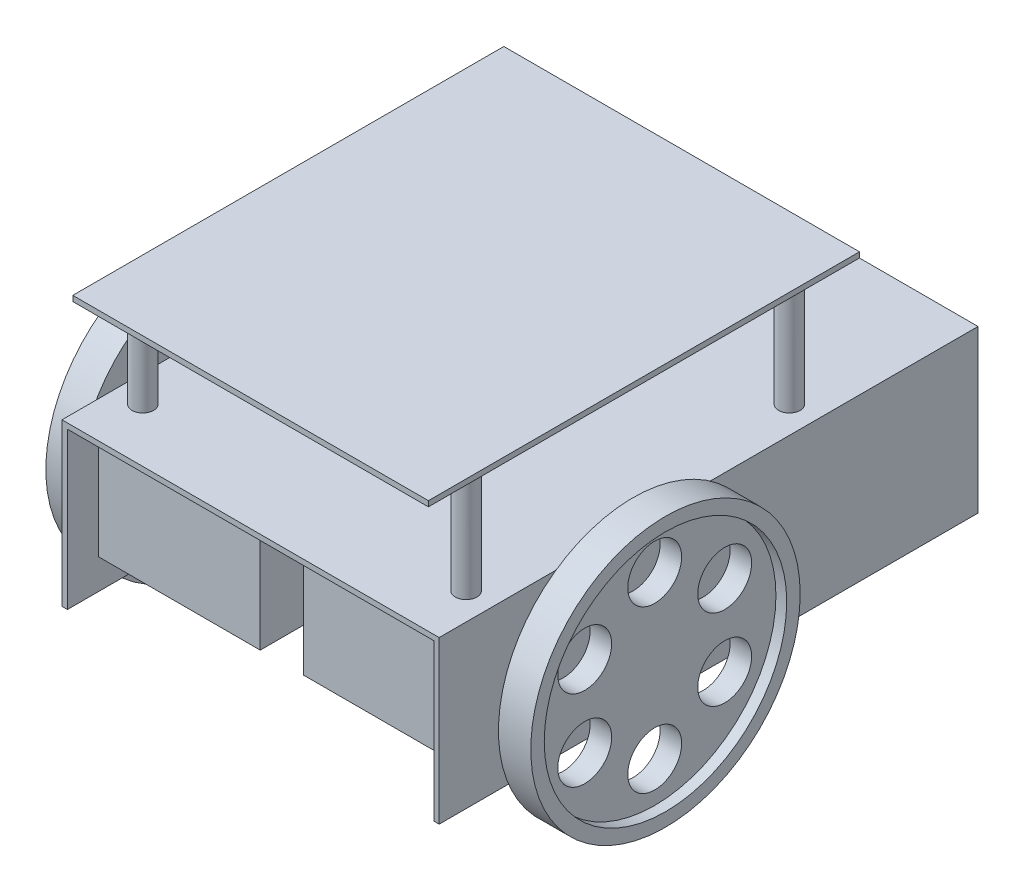
from build123d import *

# Parameters (mm, degrees)
SKETCH_1_W               = 70
SKETCH_1_H               = 100
EXTRUDE_1_DEPTH          = 30
SHELL_1_T                = -1
SKETCH_2_W               = 40
SKETCH_2_H               = 20
EXTRUDE_2_DEPTH          = 30
SKETCH_3_R               = 1.5
EXTRUDE_3_DEPTH          = 10
SKETCH_4_R               = 25
EXTRUDE_4_DEPTH          = 6
SKETCH_5_R               = 22.5
CUT_EXTRUDE_1_DEPTH      = 2
SKETCH_6_R               = 5
CUT_EXTRUDE_2_DEPTH      = 8
PATTERN_CIRCULAR_1_COUNT = 6
MIRROR_1_COPY_1_SKETCH_R = 5
MIRROR_1_COPY_1_DEPTH    = 8
MIRROR_1_COPY_2_SKETCH_R = 5
MIRROR_1_COPY_2_DEPTH    = 8
MIRROR_1_COPY_3_SKETCH_R = 5
MIRROR_1_COPY_3_DEPTH    = 8
MIRROR_1_COPY_4_SKETCH_R = 5
MIRROR_1_COPY_4_DEPTH    = 8
MIRROR_1_COPY_5_SKETCH_R = 5
MIRROR_1_COPY_5_DEPTH    = 8
SKETCH_9_R               = 14
CUT_EXTRUDE_4_DEPTH      = 8
SKETCH_8_W               = 3
SKETCH_8_H               = 29
CUT_EXTRUDE_3_DEPTH      = 8
SKETCH_10_R              = 1
EXTRUDE_5_DEPTH          = 14
SKETCH_11_R              = 2
EXTRUDE_6_DEPTH          = 20
SKETCH_12_W              = 66
SKETCH_12_H              = 80
EXTRUDE_7_DEPTH          = 1


with BuildPart() as part:
    # 草圖1 → 填料-伸長1 (new body)
    with BuildSketch(Plane(origin=(0, 0, 0), x_dir=(1, 0, 0), z_dir=(0, 1, 0))):
        with Locations((0, 50)):
            Rectangle(SKETCH_1_W, SKETCH_1_H)
    extrude(amount=EXTRUDE_1_DEPTH)

    # 薄殼1
    shell_1_openings = [part.faces().sort_by_distance(p)[0] for p in [
        (0, 0, -50),
        (0, 15, 0),
    ]]
    offset(amount=SHELL_1_T, openings=shell_1_openings, kind=Kind.INTERSECTION)

    # 草圖2 → 填料-伸長2 (add)
    with BuildSketch(Plane.ZY.offset(-34)):
        with Locations((-25.793166275, 15.578551741)):
            Rectangle(SKETCH_2_W, SKETCH_2_H)
    extrude_2 = extrude(amount=EXTRUDE_2_DEPTH)

    # 草圖3 → 填料-伸長3 (add)
    with BuildSketch(Plane(origin=(35, 0, 0), x_dir=(0, 0, -1), z_dir=(1, 0, 0))):
        with Locations((32, 13.5)):
            Circle(SKETCH_3_R)
    extrude_3 = extrude(amount=EXTRUDE_3_DEPTH)

    # 草圖4 → 填料-伸長4 (add)
    with BuildSketch(Plane(origin=(45, 0, 0), x_dir=(0, 0, -1), z_dir=(1, 0, 0))):
        with Locations((32, 13.5)):
            Circle(SKETCH_4_R)
    extrude_4 = extrude(amount=-EXTRUDE_4_DEPTH)

    # 草圖5 → 除料-伸長1 (cut)
    with BuildSketch(Plane(origin=(45, 0, 0), x_dir=(0, 0, -1), z_dir=(1, 0, 0))):
        with Locations((32, 13.5)):
            Circle(SKETCH_5_R)
    cut_extrude_1 = extrude(amount=-CUT_EXTRUDE_1_DEPTH, mode=Mode.SUBTRACT)

    # 草圖6 → 除料-伸長2 (cut)
    with BuildSketch(Plane(origin=(43, 0, 0), x_dir=(0, 0, -1), z_dir=(1, 0, 0))):
        with Locations((32, 28.5)):
            Circle(SKETCH_6_R)
    cut_extrude_2 = extrude(amount=-CUT_EXTRUDE_2_DEPTH, mode=Mode.SUBTRACT)

    # 環狀複製排列1: 除料-伸長2 ×6 about axis
    pattern_circular_1_axis = Axis((0, 13.5, -32), (1, 0, 0))
    for i in range(1, PATTERN_CIRCULAR_1_COUNT):
        add(cut_extrude_2.rotate(pattern_circular_1_axis, i * 360 / PATTERN_CIRCULAR_1_COUNT), mode=Mode.SUBTRACT)

    # 鏡射1: 填料-伸長2, 填料-伸長3, 填料-伸長4, 除料-伸長1, 除料-伸長2 across plane
    add(extrude_2.mirror(Plane(origin=(0, 0, 0), x_dir=(0, 0, 1), z_dir=(1, 0, 0))))
    add(extrude_3.mirror(Plane(origin=(0, 0, 0), x_dir=(0, 0, 1), z_dir=(1, 0, 0))))
    add(extrude_4.mirror(Plane(origin=(0, 0, 0), x_dir=(0, 0, 1), z_dir=(1, 0, 0))))
    add(cut_extrude_1.mirror(Plane(origin=(0, 0, 0), x_dir=(0, 0, 1), z_dir=(1, 0, 0))), mode=Mode.SUBTRACT)
    add(cut_extrude_2.mirror(Plane(origin=(0, 0, 0), x_dir=(0, 0, 1), z_dir=(1, 0, 0))), mode=Mode.SUBTRACT)

    # 鏡射1 copy 1 sketch → 鏡射1 copy 1 (cut)
    with BuildSketch(Plane(origin=(-43, -20.962812921, -27.691342951), x_dir=(0, 0.866025404, -0.5), z_dir=(-1, 0, 0))):
        with Locations((32, -28.5)):
            Circle(MIRROR_1_COPY_1_SKETCH_R)
    extrude(amount=-MIRROR_1_COPY_1_DEPTH, mode=Mode.SUBTRACT)

    # 鏡射1 copy 2 sketch → 鏡射1 copy 2 (cut)
    with BuildSketch(Plane(origin=(-43, -7.462812921, -59.691342951), x_dir=(0, 0.866025404, 0.5), z_dir=(-1, 0, 0))):
        with Locations((32, -28.5)):
            Circle(MIRROR_1_COPY_2_SKETCH_R)
    extrude(amount=-MIRROR_1_COPY_2_DEPTH, mode=Mode.SUBTRACT)

    # 鏡射1 copy 3 sketch → 鏡射1 copy 3 (cut)
    with BuildSketch(Plane(origin=(-43, 27, -64), x_dir=(0, 0, 1), z_dir=(-1, 0, 0))):
        with Locations((32, -28.5)):
            Circle(MIRROR_1_COPY_3_SKETCH_R)
    extrude(amount=-MIRROR_1_COPY_3_DEPTH, mode=Mode.SUBTRACT)

    # 鏡射1 copy 4 sketch → 鏡射1 copy 4 (cut)
    with BuildSketch(Plane(origin=(-43, 47.962812921, -36.308657049), x_dir=(0, -0.866025404, 0.5), z_dir=(-1, 0, 0))):
        with Locations((32, -28.5)):
            Circle(MIRROR_1_COPY_4_SKETCH_R)
    extrude(amount=-MIRROR_1_COPY_4_DEPTH, mode=Mode.SUBTRACT)

    # 鏡射1 copy 5 sketch → 鏡射1 copy 5 (cut)
    with BuildSketch(Plane(origin=(-43, 34.462812921, -4.308657049), x_dir=(0, -0.866025404, -0.5), z_dir=(-1, 0, 0))):
        with Locations((32, -28.5)):
            Circle(MIRROR_1_COPY_5_SKETCH_R)
    extrude(amount=-MIRROR_1_COPY_5_DEPTH, mode=Mode.SUBTRACT)

    # 草圖9 → 除料-伸長4 (cut)
    with BuildSketch(Plane(origin=(0, 0, -100), x_dir=(-1, 0, 0), z_dir=(0, 0, -1))):
        Circle(SKETCH_9_R)
    extrude(amount=-CUT_EXTRUDE_4_DEPTH, mode=Mode.SUBTRACT)

    # 草圖8 → 除料-伸長3 (cut)
    with BuildSketch(Plane(origin=(0, 0, -100), x_dir=(-1, 0, 0), z_dir=(0, 0, -1))):
        with Locations((32.5, 14.5)):
            Rectangle(SKETCH_8_W, SKETCH_8_H)
        with Locations((-32.5, 14.5)):
            Rectangle(SKETCH_8_W, SKETCH_8_H)
    extrude(amount=-CUT_EXTRUDE_3_DEPTH, mode=Mode.SUBTRACT)



with BuildPart() as body_2:
    # 草圖7 → 旋轉1 (revolve)
    with BuildSketch(Plane(origin=(0, 0, -100), x_dir=(-1, 0, 0), z_dir=(0, 0, -1))):
        with BuildLine():
            Line((-12, 0), (12, 0))
            ThreePointArc((12, 0), (0, 12), (-12, 0))
        make_face()
    revolve(axis=Axis((12, 0, -100), (-1, 0, 0)))


with BuildPart() as part_1:
    add(part.part)

    add(body_2.part)  # 填料-伸長5 merges body 2
    # 草圖10 → 填料-伸長5 (add, symmetric)
    with BuildSketch(Plane(origin=(0, 0, 0), x_dir=(0, 0, -1), z_dir=(1, 0, 0))):
        with Locations((100, 0)):
            Circle(SKETCH_10_R)
    extrude(amount=EXTRUDE_5_DEPTH, both=True)

    # 草圖11 → 填料-伸長6 (add)
    with BuildSketch(Plane(origin=(0, 30, 0), x_dir=(1, 0, 0), z_dir=(0, 1, 0))):
        with Locations((30, 70)):
            Circle(SKETCH_11_R)
        with Locations((-30, 70)):
            Circle(SKETCH_11_R)
        with Locations((-30, 10)):
            Circle(SKETCH_11_R)
        with Locations((30, 10)):
            Circle(SKETCH_11_R)
    extrude(amount=EXTRUDE_6_DEPTH)

    # 草圖12 → 填料-伸長7 (add)
    with BuildSketch(Plane(origin=(0, 50, 0), x_dir=(1, 0, 0), z_dir=(0, 1, 0))):
        with Locations((0, 40)):
            Rectangle(SKETCH_12_W, SKETCH_12_H)
    extrude(amount=EXTRUDE_7_DEPTH)


solid = part_1.part
